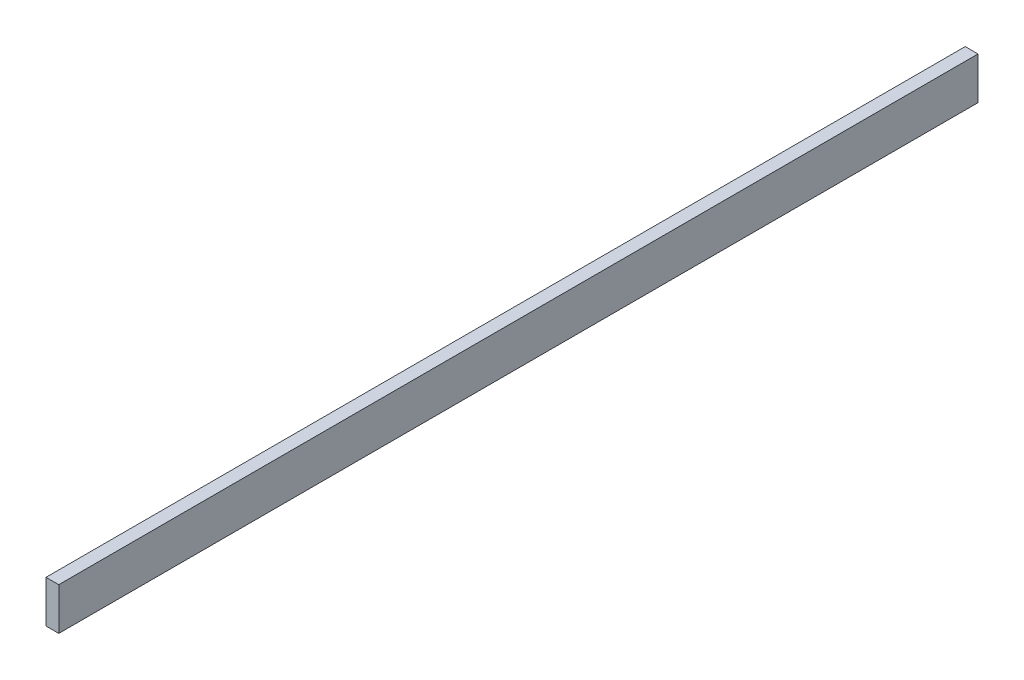
from build123d import *

# Parameters (mm, degrees)
SKETCH1_W           = 6.35
SKETCH1_H           = 21
BOSS_EXTRUDE1_DEPTH = 457.2


with BuildPart() as part:
    # Sketch1 → Boss-Extrude1 (new body)
    with BuildSketch(Plane.XY):
        Rectangle(SKETCH1_W, SKETCH1_H)
    extrude(amount=BOSS_EXTRUDE1_DEPTH)


solid = part.part
